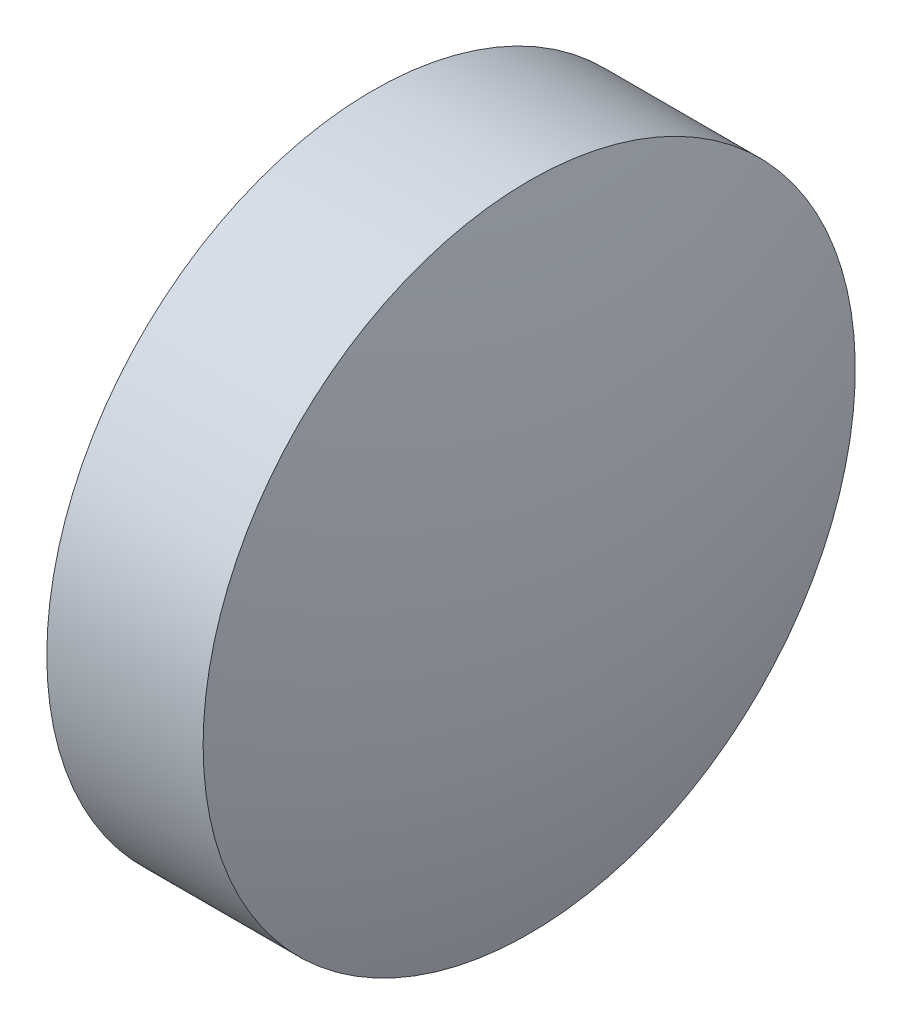
from build123d import *


with BuildPart() as part:
    # 草图1 → 旋转1 (revolve)
    with BuildSketch(Plane.XY):
        with BuildLine():
            Line((497.586594138, 112.788882016), (497.586594138, 115.938882016))
            Line((497.586594138, 115.938882016), (499.096594138, 115.938882016))
            ThreePointArc((499.096594138, 115.938882016), (499.463361921, 114.382823671), (499.586594138, 112.788882016))
            Line((499.586594138, 112.788882016), (497.586594138, 112.788882016))
        make_face()
    revolve(axis=Axis((479.100014302, 112.788882016, 0), (1, 0, 0)))


solid = part.part
